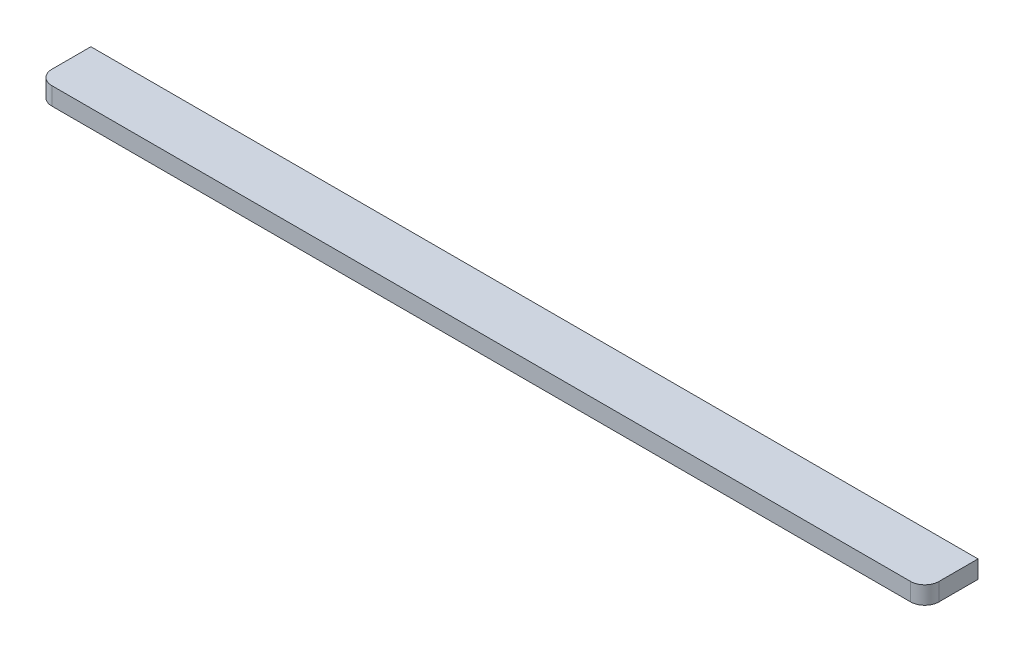
from build123d import *

# Parameters (mm, degrees)
SALIENTE_EXTRUIR1_DEPTH = 5


with BuildPart() as part:
    # Croquis1 → Saliente-Extruir1 (new body)
    with BuildSketch(Plane(origin=(0, 0, 0), x_dir=(1, 0, 0), z_dir=(0, 1, 0))):
        with BuildLine():
            Line((4, 0), (246, 0))
            ThreePointArc((246, 0), (248.828427125, 1.171572875), (250, 4))
            Line((250, 4), (250, 15))
            Line((250, 15), (0, 15))
            Line((0, 15), (0, 4))
            ThreePointArc((0, 4), (1.171572875, 1.171572875), (4, 0))
        make_face()
    extrude(amount=SALIENTE_EXTRUIR1_DEPTH)


solid = part.part
